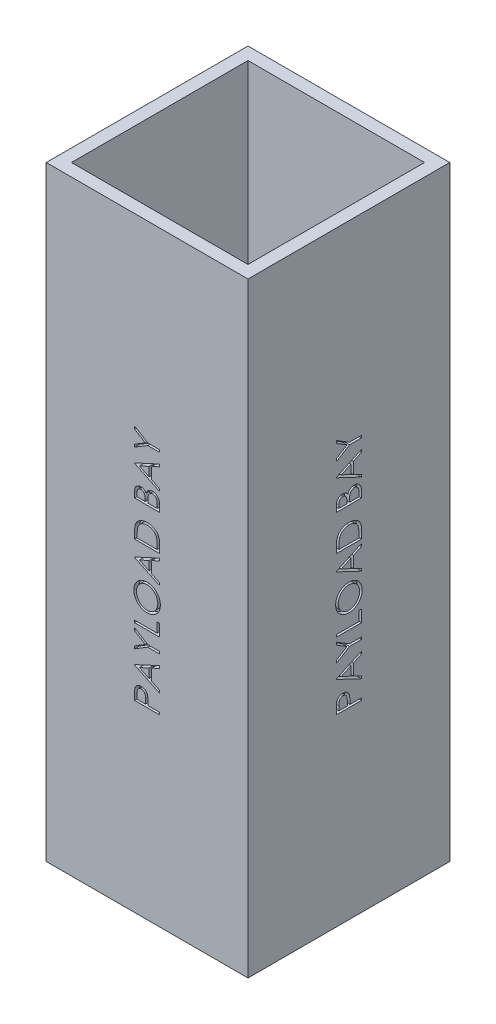
from build123d import *

# Parameters (mm, degrees)
SKETCH1_W           = 101.6
SKETCH1_H           = 101.6
SKETCH1_W_2         = 88.9
SKETCH1_H_2         = 88.9
BOSS_EXTRUDE1_DEPTH = 304.8
CUT_EXTRUDE1_DEPTH  = 2.54
CIRPATTERN1_COUNT   = 4


with BuildPart() as part:
    # Sketch1 → Boss-Extrude1 (new body)
    with BuildSketch(Plane(origin=(0, 0, 0), x_dir=(1, 0, 0), z_dir=(0, 1, 0))):
        Rectangle(SKETCH1_W, SKETCH1_H)
        Rectangle(SKETCH1_W_2, SKETCH1_H_2, mode=Mode.SUBTRACT)
    extrude(amount=BOSS_EXTRUDE1_DEPTH)

    # Sketch6 → Cut-Extrude1 (cut)
    with BuildSketch(Plane.ZY.offset(50.8)):
        with BuildLine():
            Line((-6.35, 92.482051282), (-6.35, 94.972696314))
            add(Edge.make_bspline(
                [(-6.35, 94.972696314), (-6.349811691, 95.144004459), (-6.349450882, 95.472238473), (-6.338511661, 95.942918818), (-6.323900522, 96.370399844), (-6.303646223, 96.753759798), (-6.279710024, 97.094178211), (-6.246138339, 97.390114698), (-6.211085266, 97.643895374), (-6.175447591, 97.795955919), (-6.159194712, 97.865304487)],
                knots=[0, 0, 0, 0, 0.000513909, 0.000984672, 0.001412348, 0.001797041, 0.002136358, 0.002435846, 0.002690583, 0.002904164, 0.002904164, 0.002904164, 0.002904164], degree=3))
            add(Edge.make_bspline(
                [(-6.159194712, 97.865304487), (-6.135165553, 97.953091687), (-6.087673454, 98.126597491), (-5.99256869, 98.376620926), (-5.879734333, 98.614446609), (-5.751382729, 98.841136022), (-5.601195819, 99.052560376), (-5.439164902, 99.255767619), (-5.254818851, 99.443584549), (-5.053971996, 99.618555122), (-4.839171698, 99.780275569), (-4.60651531, 99.916149986), (-4.36294889, 100.034954344), (-4.105162168, 100.132225501), (-3.832904869, 100.204560375), (-3.548111823, 100.258261731), (-3.250462794, 100.292503698), (-3.047042823, 100.295772087), (-2.943489583, 100.297435897)],
                knots=[0, 0, 0, 0, 0.000272928, 0.000539425, 0.000801167, 0.00106213, 0.001319735, 0.001578393, 0.001841062, 0.00210791, 0.002377077, 0.00264628, 0.002914809, 0.003189345, 0.003471382, 0.003758783, 0.004058271, 0.004368814, 0.004368814, 0.004368814, 0.004368814], degree=3))
            add(Edge.make_bspline(
                [(-2.943489583, 100.297435897), (-2.839067365, 100.295906728), (-2.634758241, 100.292914804), (-2.335862696, 100.257005426), (-2.050227394, 100.208635873), (-1.778485674, 100.134260855), (-1.522251307, 100.036849412), (-1.277608551, 99.922578249), (-1.048719455, 99.784752296), (-0.834753057, 99.626383914), (-0.635508519, 99.450210986), (-0.452429693, 99.256978896), (-0.286588236, 99.047467749), (-0.137612361, 98.822343383), (-0.008956718, 98.579411074), (0.106276931, 98.32235526), (0.20305478, 98.048941618), (0.25396386, 97.859738781), (0.279847756, 97.763541667)],
                knots=[0, 0, 0, 0, 0.000313086, 0.000612574, 0.000902017, 0.001181599, 0.001456135, 0.001723565, 0.001990583, 0.002256192, 0.00252113, 0.002787469, 0.003053674, 0.003321805, 0.003596116, 0.003877417, 0.00416629, 0.004465075, 0.004465075, 0.004465075, 0.004465075], degree=3))
            add(Edge.make_bspline(
                [(0.279847756, 97.763541667), (0.296755106, 97.683975863), (0.333808547, 97.509602778), (0.375455577, 97.222445764), (0.409610691, 96.88794002), (0.441484518, 96.507223684), (0.458373661, 96.079408932), (0.47820427, 95.605476968), (0.487561251, 95.083823846), (0.488152728, 94.719987058), (0.488461538, 94.530028045)],
                knots=[0, 0, 0, 0, 0.000243979, 0.000534694, 0.000869865, 0.001252695, 0.001680583, 0.002154115, 0.002675749, 0.003245626, 0.003245626, 0.003245626, 0.003245626], degree=3))
            Line((0.488461538, 94.530028045), (0.488461538, 93.621794872))
            Line((0.488461538, 93.621794872), (6.35, 93.621794872))
            Line((6.35, 93.621794872), (6.35, 92.482051282))
            Line((6.35, 92.482051282), (-6.35, 92.482051282))
        make_face()
        with BuildLine():
            Line((-5.047435897, 93.621794872), (-0.814102564, 93.621794872))
            Line((-0.814102564, 93.621794872), (-0.786117788, 95.8453125))
            add(Edge.make_bspline(
                [(-0.786117788, 95.8453125), (-0.786058006, 95.953879847), (-0.785942597, 96.163466872), (-0.800452377, 96.466211014), (-0.816979073, 96.747130601), (-0.841974741, 97.005169257), (-0.874740105, 97.24123239), (-0.915487111, 97.453280991), (-0.959785588, 97.644486591), (-1.033797354, 97.864431594), (-1.147598039, 98.111657023), (-1.313260324, 98.381731934), (-1.527867901, 98.608844847), (-1.768488369, 98.80501689), (-2.035447832, 98.963756171), (-2.322580965, 99.075740401), (-2.62563392, 99.144695668), (-2.832880378, 99.15330752), (-2.938401442, 99.157692308)],
                knots=[0, 0, 0, 0, 0.000325651, 0.000628662, 0.000909076, 0.001169816, 0.001406195, 0.001623739, 0.00181749, 0.001994481, 0.002318937, 0.002632302, 0.002940177, 0.003251283, 0.003561503, 0.003867638, 0.004172555, 0.00448885, 0.00448885, 0.00448885, 0.00448885], degree=3))
            add(Edge.make_bspline(
                [(-2.938401442, 99.157692308), (-3.040503948, 99.153110659), (-3.243471094, 99.144002909), (-3.540938354, 99.076309447), (-3.824816581, 98.962553668), (-4.089626181, 98.804878111), (-4.329717186, 98.61346686), (-4.538638533, 98.391169219), (-4.705467251, 98.137416482), (-4.81729303, 97.903335586), (-4.882763075, 97.693719024), (-4.930049703, 97.512545142), (-4.962657093, 97.306933975), (-4.993858298, 97.078839141), (-5.019043897, 96.828550238), (-5.036533738, 96.554476492), (-5.046662216, 96.257530593), (-5.04717176, 96.051390347), (-5.047435897, 95.94453125)],
                knots=[0, 0, 0, 0, 0.000306146, 0.00060858, 0.000909985, 0.001220206, 0.001529716, 0.001828533, 0.002131234, 0.002437391, 0.002603127, 0.00278947, 0.002998595, 0.003227067, 0.003480211, 0.003753009, 0.004050839, 0.004371402, 0.004371402, 0.004371402, 0.004371402], degree=3))
            Line((-5.047435897, 95.94453125), (-5.047435897, 93.621794872))
        make_face(mode=Mode.SUBTRACT)
        Polygon((-6.35, 108.112820513), (6.35, 113.974358974), (6.35, 112.735396635), (2.279487179, 110.857872596), (2.279487179, 105.100641026), (6.35, 103.169691506), (6.35, 101.925641026), (-6.35, 107.95), align=None)
        Polygon((-3.874619391, 108.018689904), (0.976923077, 105.71885016), (0.976923077, 110.257471955), align=None, mode=Mode.SUBTRACT)
        Polygon((-6.35, 114.951282051), (-6.35, 116.256390224), (-0.89296875, 119.594210737), (-6.35, 122.926943109), (-6.35, 124.232051282), (0.312920673, 120.161538462), (6.35, 120.161538462), (6.35, 119.021794872), (0.312920673, 119.021794872), align=None)
        Polygon((-6.35, 126.348717949), (-6.35, 127.488461538), (5.047435897, 127.488461538), (5.047435897, 132.373076923), (6.35, 132.373076923), (6.35, 126.348717949), align=None)
        with BuildLine():
            add(Edge.make_bspline(
                [(-6.675641026, 140.432692308), (-6.669785071, 140.667878789), (-6.658283492, 141.129804442), (-6.567334124, 141.808062537), (-6.41764098, 142.457525074), (-6.206242297, 143.078565423), (-5.932190469, 143.668821615), (-5.599295982, 144.229960687), (-5.205535771, 144.760300963), (-4.756691829, 145.256191897), (-4.26513446, 145.708559312), (-3.738912975, 146.105514067), (-3.184643364, 146.440382863), (-2.60229672, 146.714509446), (-1.99323266, 146.929716981), (-1.354037691, 147.078184212), (-0.688898346, 147.17303121), (-0.235229152, 147.184118924), (-0.005088141, 147.18974359)],
                knots=[0, 0, 0, 0, 0.000705368, 0.001385402, 0.0020488, 0.002702076, 0.003349741, 0.00399766, 0.004656078, 0.005327949, 0.006001364, 0.006657226, 0.007302086, 0.007940532, 0.008585026, 0.009236039, 0.009906328, 0.010596447, 0.010596447, 0.010596447, 0.010596447], degree=3))
            add(Edge.make_bspline(
                [(-0.005088141, 147.18974359), (0.223356266, 147.184117031), (0.673646657, 147.173026431), (1.334584132, 147.078107253), (1.969850898, 146.929054513), (2.578031024, 146.717174008), (3.159194899, 146.442837073), (3.71388411, 146.107475299), (4.241511135, 145.711273919), (4.736454933, 145.260827488), (5.189213913, 144.768333696), (5.588564969, 144.244134632), (5.923579539, 143.6898798), (6.200766497, 143.111312922), (6.411489139, 142.503890905), (6.56490218, 141.872033968), (6.658807614, 141.212299547), (6.669968316, 140.762882653), (6.675641026, 140.534455128)],
                knots=[0, 0, 0, 0, 0.000685036, 0.001350284, 0.001998823, 0.002640075, 0.00327852, 0.003923381, 0.004581277, 0.005254856, 0.005928271, 0.006585666, 0.00722835, 0.007867883, 0.008506734, 0.009153393, 0.009816123, 0.010501158, 0.010501158, 0.010501158, 0.010501158], degree=3))
            add(Edge.make_bspline(
                [(6.675641026, 140.534455128), (6.670018965, 140.304315456), (6.658936386, 139.850648902), (6.563935289, 139.184671659), (6.415376844, 138.545035274), (6.203071175, 137.933568914), (5.928688652, 137.349931598), (5.594118477, 136.792981869), (5.19712685, 136.264955249), (4.746579565, 135.770229483), (4.256099934, 135.317568107), (3.730558494, 134.922926944), (3.180265837, 134.588281533), (2.603694821, 134.314820298), (2.003632729, 134.098323545), (1.376076825, 133.950623205), (0.724604903, 133.855061322), (0.281037815, 133.844049165), (0.055969551, 133.838461538)],
                knots=[0, 0, 0, 0, 0.000690119, 0.001360408, 0.002013897, 0.002657552, 0.003298299, 0.003945339, 0.004603236, 0.005276814, 0.005950229, 0.006602529, 0.007245213, 0.007879059, 0.008513962, 0.009155077, 0.009810248, 0.010485118, 0.010485118, 0.010485118, 0.010485118], degree=3))
            add(Edge.make_bspline(
                [(0.055969551, 133.838461538), (-0.095097562, 133.840401502), (-0.395326011, 133.844256954), (-0.841156245, 133.890672524), (-1.279816632, 133.958024983), (-1.710059786, 134.054551923), (-2.130832502, 134.180795971), (-2.545036699, 134.329756185), (-2.948474782, 134.511692195), (-3.343057946, 134.717361975), (-3.722635205, 134.946911965), (-4.081426835, 135.200461113), (-4.422443595, 135.469103735), (-4.736848437, 135.763610906), (-5.033787705, 136.074276293), (-5.308698135, 136.406139551), (-5.564058671, 136.757175695), (-5.794183909, 137.128895187), (-6.002315626, 137.512138642), (-6.180920628, 137.907205807), (-6.33421348, 138.308731081), (-6.45845876, 138.718595089), (-6.556546433, 139.135709433), (-6.623338831, 139.56098448), (-6.669872784, 139.994081427), (-6.673710006, 140.285859641), (-6.675641026, 140.432692308)],
                knots=[0, 0, 0, 0, 0.000453023, 0.000900331, 0.00134327, 0.001783953, 0.002221843, 0.002660465, 0.003103469, 0.003548398, 0.003994743, 0.004433047, 0.004865726, 0.005295975, 0.005724256, 0.006154227, 0.006587795, 0.007025471, 0.007464852, 0.007895214, 0.008325184, 0.00875333, 0.009179133, 0.00960951, 0.010044159, 0.010484467, 0.010484467, 0.010484467, 0.010484467], degree=3))
        make_face()
        with BuildLine():
            add(Edge.make_bspline(
                [(-5.373076923, 140.488661859), (-5.371612874, 140.368138647), (-5.368698771, 140.128244435), (-5.330103131, 139.771634762), (-5.275488499, 139.419606801), (-5.196168901, 139.072841773), (-5.093572448, 138.730612447), (-4.969833028, 138.392766886), (-4.820275395, 138.060463451), (-4.652079665, 137.734117284), (-4.461036223, 137.421265912), (-4.258166746, 137.121155899), (-4.035933534, 136.841593359), (-3.799142721, 136.578737887), (-3.545739327, 136.333243177), (-3.277387483, 136.105217516), (-2.992926494, 135.894847893), (-2.693527038, 135.704666015), (-2.380860728, 135.535418989), (-2.060904396, 135.383885031), (-1.729897889, 135.258269162), (-1.389906788, 135.158762678), (-1.042429358, 135.074304473), (-0.685572416, 135.021326036), (-0.320566176, 134.982350109), (-0.073887757, 134.979597426), (0.05088141, 134.978205128)],
                knots=[0, 0, 0, 0, 0.000361401, 0.000719348, 0.001074863, 0.001429731, 0.001785501, 0.002146095, 0.002508248, 0.002878058, 0.003246738, 0.003607323, 0.00396412, 0.004317168, 0.004668001, 0.005021764, 0.005372855, 0.005728561, 0.006084895, 0.00643885, 0.006789913, 0.007145683, 0.007501125, 0.007861666, 0.008227207, 0.008601324, 0.008601324, 0.008601324, 0.008601324], degree=3))
            add(Edge.make_bspline(
                [(0.05088141, 134.978205128), (0.234345869, 134.98284164), (0.595277215, 134.991963092), (1.124266852, 135.071486696), (1.63314324, 135.194954947), (2.118873279, 135.373960588), (2.583622971, 135.602317606), (3.025583679, 135.880866807), (3.444625029, 136.212159116), (3.837627676, 136.588256745), (4.19619396, 136.999509589), (4.511375607, 137.435990281), (4.776641272, 137.894245547), (4.998397407, 138.371634123), (5.165459253, 138.87223187), (5.284574271, 139.392829147), (5.361776101, 139.933437463), (5.369274234, 140.301830698), (5.373076923, 140.488661859)],
                knots=[0, 0, 0, 0, 0.000550108, 0.001082232, 0.001601154, 0.002118677, 0.00263181, 0.003152009, 0.003682843, 0.004231661, 0.004781633, 0.005317521, 0.005844193, 0.006367833, 0.006893982, 0.007424089, 0.007968455, 0.008528619, 0.008528619, 0.008528619, 0.008528619], degree=3))
            add(Edge.make_bspline(
                [(5.373076923, 140.488661859), (5.371352914, 140.614245402), (5.367933685, 140.863315285), (5.333446658, 141.233768939), (5.278253288, 141.597582943), (5.198393676, 141.954085094), (5.099767851, 142.303742487), (4.97743268, 142.645500082), (4.830782133, 142.979244366), (4.667344949, 143.306616436), (4.481684714, 143.620286113), (4.281550104, 143.918575726), (4.063238117, 144.197656623), (3.829627504, 144.460388767), (3.57700307, 144.704162974), (3.310282099, 144.9315394), (3.025217373, 145.138271673), (2.727044186, 145.327808831), (2.416657403, 145.499120929), (2.095821442, 145.646271725), (1.766257055, 145.771941549), (1.427722103, 145.873245665), (1.080978091, 145.952668472), (0.725528754, 146.007384366), (0.362093818, 146.045660851), (0.116280345, 146.048545747), (-0.007632212, 146.05)],
                knots=[0, 0, 0, 0, 0.00037666, 0.00074703, 0.001115112, 0.001479909, 0.001842294, 0.002204411, 0.002567866, 0.002935359, 0.003301431, 0.003660587, 0.004012239, 0.004363588, 0.004714421, 0.005064598, 0.005414184, 0.00576989, 0.006123991, 0.006476875, 0.006827938, 0.007181271, 0.007536139, 0.007894167, 0.008259708, 0.008631282, 0.008631282, 0.008631282, 0.008631282], degree=3))
            add(Edge.make_bspline(
                [(-0.007632212, 146.05), (-0.130697041, 146.048544533), (-0.374818801, 146.045657346), (-0.735719484, 146.007403224), (-1.088609709, 145.952608564), (-1.432104078, 145.873641023), (-1.766290161, 145.77185904), (-2.090854054, 145.646356428), (-2.407005009, 145.498364107), (-2.713961172, 145.328516926), (-3.008510573, 145.137597379), (-3.290092515, 144.928972715), (-3.553442649, 144.699057084), (-3.804973342, 144.45435931), (-4.03965346, 144.188996329), (-4.256576238, 143.902921828), (-4.465515493, 143.603258692), (-4.650429047, 143.283230258), (-4.822051388, 142.954134185), (-4.968471586, 142.616134055), (-5.094225799, 142.274057007), (-5.196475173, 141.926535353), (-5.275184667, 141.573733358), (-5.330152005, 141.215856192), (-5.368685515, 140.854153049), (-5.371608475, 140.610878865), (-5.373076923, 140.488661859)],
                knots=[0, 0, 0, 0, 0.000369031, 0.00073204, 0.001087555, 0.001439943, 0.001788407, 0.002134718, 0.002482986, 0.00283486, 0.003186283, 0.003535331, 0.003885231, 0.004234241, 0.004587492, 0.004946738, 0.00531086, 0.005682608, 0.006054677, 0.006423813, 0.006786796, 0.007147444, 0.007509758, 0.007870298, 0.008233308, 0.008599795, 0.008599795, 0.008599795, 0.008599795], degree=3))
        make_face(mode=Mode.SUBTRACT)
        Polygon((-6.35, 155.005128205), (6.35, 160.866666667), (6.35, 159.627704327), (2.279487179, 157.750180288), (2.279487179, 151.992948718), (6.35, 150.061999199), (6.35, 148.817948718), (-6.35, 154.842307692), align=None)
        Polygon((-3.874619391, 154.910997596), (0.976923077, 152.611157853), (0.976923077, 157.149779647), align=None, mode=Mode.SUBTRACT)
        with BuildLine():
            Line((6.35, 162.820512821), (-6.35, 162.820512821))
            Line((-6.35, 162.820512821), (-6.35, 165.384935897))
            add(Edge.make_bspline(
                [(-6.35, 165.384935897), (-6.348394103, 165.607980512), (-6.345291519, 166.038901546), (-6.325619614, 166.66160957), (-6.290819923, 167.237767793), (-6.2401305, 167.765481311), (-6.177889492, 168.246198851), (-6.099873739, 168.678574372), (-6.00775095, 169.064843576), (-5.929208887, 169.302404118), (-5.892067308, 169.41474359)],
                knots=[0, 0, 0, 0, 0.000669134, 0.001292764, 0.001868826, 0.002400433, 0.002882928, 0.003322552, 0.003718071, 0.004072903, 0.004072903, 0.004072903, 0.004072903], degree=3))
            add(Edge.make_bspline(
                [(-5.892067308, 169.41474359), (-5.836093327, 169.561694877), (-5.725414669, 169.852265085), (-5.51631439, 170.265755961), (-5.280367806, 170.656337905), (-5.012145128, 171.020896847), (-4.715148895, 171.36034751), (-4.391500844, 171.678542555), (-4.034011275, 171.96763688), (-3.649043287, 172.232133132), (-3.241529407, 172.470675187), (-2.812137035, 172.67800451), (-2.363076518, 172.850195854), (-1.895588611, 172.993136678), (-1.408647571, 173.105791053), (-0.9016858, 173.182651182), (-0.376707035, 173.233345923), (-0.02047398, 173.238440622), (0.160276442, 173.241025641)],
                knots=[0, 0, 0, 0, 0.000471477, 0.000932263, 0.001387773, 0.001839114, 0.00228809, 0.002739654, 0.00319897, 0.003665423, 0.00413972, 0.004614208, 0.005094222, 0.005581098, 0.006079742, 0.006592118, 0.007118421, 0.007660523, 0.007660523, 0.007660523, 0.007660523], degree=3))
            add(Edge.make_bspline(
                [(0.160276442, 173.241025641), (0.317252935, 173.238743386), (0.626591509, 173.234245964), (1.082488494, 173.193862471), (1.52486052, 173.135165446), (1.951601475, 173.044291121), (2.366448593, 172.933972212), (2.764986355, 172.792592467), (3.150849201, 172.630613026), (3.518898525, 172.441806471), (3.867366737, 172.234246367), (4.196106488, 172.012889743), (4.497822934, 171.772716402), (4.780422415, 171.520834747), (5.036355603, 171.251170688), (5.270287817, 170.967007346), (5.478302523, 170.667240384), (5.663668473, 170.350014161), (5.829436114, 170.01109204), (5.967706215, 169.639813205), (6.087462238, 169.237936329), (6.182728161, 168.80316961), (6.259560811, 168.337063728), (6.310716285, 167.838325694), (6.345409359, 167.307898054), (6.348440074, 166.943663461), (6.35, 166.756189904)],
                knots=[0, 0, 0, 0, 0.000470825, 0.00092781, 0.001372149, 0.001808729, 0.0022358, 0.002659019, 0.003076254, 0.003490407, 0.003898792, 0.004292531, 0.004678333, 0.00505483, 0.005427317, 0.005792478, 0.006158046, 0.006520636, 0.006893843, 0.007288379, 0.00770775, 0.008150915, 0.008622694, 0.009124186, 0.009654385, 0.010216717, 0.010216717, 0.010216717, 0.010216717], degree=3))
            Line((6.35, 166.756189904), (6.35, 162.820512821))
        make_face()
        with BuildLine():
            Line((5.047435897, 163.96025641), (5.047435897, 165.418008814))
            add(Edge.make_bspline(
                [(5.047435897, 165.418008814), (5.046535662, 165.627480331), (5.04480418, 166.030370771), (5.029610614, 166.609701218), (5.004784155, 167.139035028), (4.970040301, 167.618447362), (4.924071326, 168.047667536), (4.872818108, 168.427592571), (4.808964501, 168.75697708), (4.751085305, 168.956292466), (4.724338942, 169.048397436)],
                knots=[0, 0, 0, 0, 0.000628406, 0.001208655, 0.001738433, 0.002218042, 0.002650422, 0.003033235, 0.00336802, 0.003655635, 0.003655635, 0.003655635, 0.003655635], degree=3))
            add(Edge.make_bspline(
                [(4.724338942, 169.048397436), (4.683511867, 169.164324362), (4.602832871, 169.393409301), (4.45566639, 169.723177636), (4.281342714, 170.030725124), (4.087567265, 170.321407724), (3.867514454, 170.591116069), (3.625936061, 170.842993512), (3.36172837, 171.076731682), (3.075319806, 171.288730377), (2.769816125, 171.480752404), (2.444677018, 171.645595261), (2.104473453, 171.789151793), (1.746451287, 171.902822569), (1.373234633, 171.992446996), (0.9828882, 172.055268709), (0.575757403, 172.094269377), (0.298593328, 172.098919006), (0.157732372, 172.101282051)],
                knots=[0, 0, 0, 0, 0.000368636, 0.000728467, 0.00108158, 0.001428031, 0.001775294, 0.002124361, 0.00247402, 0.002832229, 0.003192239, 0.003555195, 0.003924673, 0.00429879, 0.004680748, 0.005075153, 0.005483989, 0.005906496, 0.005906496, 0.005906496, 0.005906496], degree=3))
            add(Edge.make_bspline(
                [(0.157732372, 172.101282051), (0.009202315, 172.099419551), (-0.282586297, 172.095760654), (-0.710723963, 172.049771013), (-1.122496609, 171.982564226), (-1.517931775, 171.885377708), (-1.897800939, 171.761531376), (-2.260003161, 171.606973676), (-2.608363686, 171.430383372), (-2.934842098, 171.220276978), (-3.243608523, 170.990168968), (-3.526473502, 170.734797806), (-3.784081392, 170.458220695), (-4.020444041, 170.163454241), (-4.226052236, 169.842191052), (-4.409972479, 169.501999089), (-4.566058713, 169.137887653), (-4.649076301, 168.8845673), (-4.691266026, 168.755829327)],
                knots=[0, 0, 0, 0, 0.000445394, 0.00087498, 0.001290296, 0.001696304, 0.002095342, 0.002487525, 0.00287666, 0.003265537, 0.003650709, 0.004030799, 0.004406986, 0.004783646, 0.005162584, 0.005549584, 0.005942765, 0.00634906, 0.00634906, 0.00634906, 0.00634906], degree=3))
            add(Edge.make_bspline(
                [(-4.691266026, 168.755829327), (-4.720717064, 168.649326596), (-4.783338052, 168.422872568), (-4.851647261, 168.053340799), (-4.911897871, 167.637451542), (-4.962908471, 167.173358341), (-4.999511037, 166.661590218), (-5.026984093, 166.101753579), (-5.045513874, 165.493606442), (-5.046779183, 165.072029819), (-5.047435897, 164.85322516)],
                knots=[0, 0, 0, 0, 0.000331365, 0.000704572, 0.001126244, 0.001592052, 0.002104832, 0.002665226, 0.00327352, 0.00392991, 0.00392991, 0.00392991, 0.00392991], degree=3))
            Line((-5.047435897, 164.85322516), (-5.047435897, 163.96025641))
            Line((-5.047435897, 163.96025641), (5.047435897, 163.96025641))
        make_face(mode=Mode.SUBTRACT)
        with BuildLine():
            Line((-6.35, 180.730769231), (-6.35, 183.20869391))
            add(Edge.make_bspline(
                [(-6.35, 183.20869391), (-6.349372317, 183.329993444), (-6.34815571, 183.565102129), (-6.32884905, 183.906958107), (-6.303182672, 184.227265278), (-6.260128703, 184.525457622), (-6.215487417, 184.80347543), (-6.149964695, 185.058496238), (-6.077592462, 185.292656163), (-5.966237959, 185.573834305), (-5.793303013, 185.892869434), (-5.536824054, 186.235772502), (-5.229326494, 186.533844772), (-4.878908769, 186.787294554), (-4.493409562, 186.990693397), (-4.081123013, 187.135981885), (-3.64898535, 187.229320743), (-3.352715027, 187.238799389), (-3.202984776, 187.243589744)],
                knots=[0, 0, 0, 0, 0.000363838, 0.000705208, 0.00102698, 0.001327407, 0.001608892, 0.001871129, 0.002116536, 0.002343771, 0.002777466, 0.0032008, 0.003623583, 0.004057151, 0.004494139, 0.004926249, 0.005365321, 0.005813951, 0.005813951, 0.005813951, 0.005813951], degree=3))
            add(Edge.make_bspline(
                [(-3.202984776, 187.243589744), (-3.062737383, 187.239599728), (-2.787138031, 187.23175897), (-2.384737295, 187.157696306), (-2.002077719, 187.040148273), (-1.639486801, 186.87769215), (-1.303714203, 186.668376526), (-0.995800058, 186.417586986), (-0.727381826, 186.116265358), (-0.577377362, 185.890393651), (-0.501181891, 185.775661058)],
                knots=[0, 0, 0, 0, 0.000420396, 0.000826117, 0.001222837, 0.001619092, 0.002014431, 0.002406622, 0.002806568, 0.003219445, 0.003219445, 0.003219445, 0.003219445], degree=3))
            add(Edge.make_bspline(
                [(-0.501181891, 185.775661058), (-0.445773816, 185.919920678), (-0.339764444, 186.195925067), (-0.152634166, 186.57596648), (0.051636421, 186.902202218), (0.271263785, 187.181005131), (0.511490195, 187.418194242), (0.774267381, 187.623613728), (1.059380217, 187.801202875), (1.365780824, 187.952330012), (1.690871704, 188.071042262), (2.030682193, 188.15829412), (2.383909628, 188.209905491), (2.623616838, 188.216946074), (2.745052083, 188.220512821)],
                knots=[0, 0, 0, 0, 0.000463447, 0.000886689, 0.001268545, 0.0016162, 0.001949007, 0.002278795, 0.002614805, 0.002954998, 0.003301897, 0.00365114, 0.00400589, 0.004370127, 0.004370127, 0.004370127, 0.004370127], degree=3))
            add(Edge.make_bspline(
                [(2.745052083, 188.220512821), (2.869029524, 188.21696904), (3.112958611, 188.209996552), (3.471291465, 188.158532445), (3.813764183, 188.071454355), (4.142434121, 187.951303705), (4.456612174, 187.795568463), (4.755160179, 187.603304589), (5.038699261, 187.377211083), (5.307729832, 187.121688874), (5.553901262, 186.836929363), (5.765525674, 186.523106054), (5.947492508, 186.188816177), (6.095643415, 185.829786154), (6.209941742, 185.446932515), (6.289576238, 185.040468299), (6.343323875, 184.611062893), (6.347736865, 184.316385354), (6.35, 184.165264423)],
                knots=[0, 0, 0, 0, 0.000371861, 0.000731647, 0.001083355, 0.001430255, 0.001779543, 0.002133105, 0.002493475, 0.002865962, 0.003244832, 0.003620227, 0.003999302, 0.004384828, 0.004783241, 0.005195859, 0.005626281, 0.006079382, 0.006079382, 0.006079382, 0.006079382], degree=3))
            Line((6.35, 184.165264423), (6.35, 180.730769231))
            Line((6.35, 180.730769231), (-6.35, 180.730769231))
        make_face()
        with BuildLine():
            Line((-5.047435897, 181.870512821), (-0.976923077, 181.870512821))
            Line((-0.976923077, 181.870512821), (-0.976923077, 182.636278045))
            add(Edge.make_bspline(
                [(-0.976923077, 182.636278045), (-0.978374226, 182.748215103), (-0.981178141, 182.964500309), (-0.989210049, 183.277718217), (-1.011700083, 183.568457579), (-1.034183694, 183.83621648), (-1.070739951, 184.080573468), (-1.114254566, 184.300986513), (-1.160274294, 184.500916987), (-1.238545357, 184.731469368), (-1.354184303, 184.993027832), (-1.533820739, 185.271677561), (-1.747610778, 185.518470549), (-1.996602328, 185.724374206), (-2.267797908, 185.894378417), (-2.558816675, 186.013471713), (-2.863802254, 186.092867668), (-3.073579537, 186.100149172), (-3.180088141, 186.103846154)],
                knots=[0, 0, 0, 0, 0.000335856, 0.000648942, 0.000939679, 0.001210548, 0.001454845, 0.001680365, 0.001884605, 0.002069641, 0.0024101, 0.002739663, 0.003060599, 0.003385683, 0.003705519, 0.004016874, 0.004326007, 0.004644839, 0.004644839, 0.004644839, 0.004644839], degree=3))
            add(Edge.make_bspline(
                [(-3.180088141, 186.103846154), (-3.250585181, 186.101969054), (-3.388872822, 186.098286917), (-3.591119209, 186.067034672), (-3.781156629, 186.01639774), (-3.960808966, 185.947821684), (-4.125611427, 185.854136614), (-4.283438701, 185.74554331), (-4.424837705, 185.611469459), (-4.556615938, 185.459954103), (-4.674557016, 185.286593511), (-4.77225292, 185.087652627), (-4.860797869, 184.868274376), (-4.926345062, 184.622506905), (-4.983983541, 184.355442602), (-5.020198184, 184.063465315), (-5.043502651, 183.748425244), (-5.046095572, 183.530142044), (-5.047435897, 183.417307692)],
                knots=[0, 0, 0, 0, 0.000211403, 0.00041469, 0.000612163, 0.000800665, 0.000989698, 0.001179568, 0.001373986, 0.00157239, 0.001781252, 0.00200084, 0.002236108, 0.002489814, 0.002762742, 0.003055266, 0.00337156, 0.003710008, 0.003710008, 0.003710008, 0.003710008], degree=3))
            Line((-5.047435897, 183.417307692), (-5.047435897, 181.870512821))
        make_face(mode=Mode.SUBTRACT)
        with BuildLine():
            Line((0.325641026, 181.870512821), (5.047435897, 181.870512821))
            Line((5.047435897, 181.870512821), (5.047435897, 183.493629808))
            add(Edge.make_bspline(
                [(5.047435897, 183.493629808), (5.045904986, 183.609800616), (5.042954355, 183.833704534), (5.036034513, 184.157237907), (5.009857802, 184.456320822), (4.985709904, 184.73189678), (4.944418036, 184.983234398), (4.905449249, 185.212266982), (4.847602867, 185.415234803), (4.768099821, 185.652754112), (4.640825315, 185.9182458), (4.454878463, 186.208380427), (4.225391341, 186.461373325), (3.964393202, 186.678544111), (3.681391572, 186.857762875), (3.380086158, 186.98636929), (3.066336778, 187.066289903), (2.852362575, 187.075933072), (2.745052083, 187.080769231)],
                knots=[0, 0, 0, 0, 0.000348575, 0.000671832, 0.000970368, 0.00124908, 0.001501302, 0.001734317, 0.001945399, 0.00213366, 0.002485313, 0.002825429, 0.003164106, 0.003505476, 0.003841486, 0.004165184, 0.004484806, 0.004806367, 0.004806367, 0.004806367, 0.004806367], degree=3))
            add(Edge.make_bspline(
                [(2.745052083, 187.080769231), (2.677946231, 187.079770435), (2.54481695, 187.077788953), (2.34920062, 187.047769991), (2.159617461, 187.004342067), (1.975277451, 186.947146241), (1.799280024, 186.867189559), (1.630950229, 186.769169369), (1.466897116, 186.656967846), (1.256812893, 186.483862119), (1.01776619, 186.228402227), (0.786615655, 185.865365211), (0.597190031, 185.454858428), (0.517108985, 185.156426067), (0.475741186, 185.002263622)],
                knots=[0, 0, 0, 0, 0.000201126, 0.000399009, 0.000592174, 0.000784466, 0.000976909, 0.00117066, 0.001368248, 0.001572487, 0.001986491, 0.00241129, 0.002858707, 0.003336803, 0.003336803, 0.003336803, 0.003336803], degree=3))
            add(Edge.make_bspline(
                [(0.475741186, 185.002263622), (0.463204167, 184.940472331), (0.436021324, 184.806496067), (0.407327657, 184.588028561), (0.381764154, 184.338615551), (0.362855097, 184.057681111), (0.343309639, 183.744869802), (0.33570843, 183.399513554), (0.326639687, 183.023022727), (0.325982428, 182.761793261), (0.325641026, 182.626101763)],
                knots=[0, 0, 0, 0, 0.000189102, 0.000410011, 0.000660625, 0.000941212, 0.001254639, 0.001600782, 0.001977382, 0.002384441, 0.002384441, 0.002384441, 0.002384441], degree=3))
            Line((0.325641026, 182.626101763), (0.325641026, 181.870512821))
        make_face(mode=Mode.SUBTRACT)
        Polygon((-6.35, 196.035897436), (6.35, 201.897435897), (6.35, 200.658473558), (2.279487179, 198.780949519), (2.279487179, 193.023717949), (6.35, 191.092768429), (6.35, 189.848717949), (-6.35, 195.873076923), align=None)
        Polygon((-3.874619391, 195.941766827), (0.976923077, 193.641927083), (0.976923077, 198.180548878), align=None, mode=Mode.SUBTRACT)
        Polygon((-6.35, 202.874358974), (-6.35, 204.179467147), (-0.89296875, 207.51728766), (-6.35, 210.850020032), (-6.35, 212.155128205), (0.312920673, 208.084615385), (6.35, 208.084615385), (6.35, 206.944871795), (0.312920673, 206.944871795), align=None)
    cut_extrude1 = extrude(amount=-CUT_EXTRUDE1_DEPTH, mode=Mode.SUBTRACT)

    # CirPattern1: Cut-Extrude1 ×4 about axis
    cirpattern1_axis = Axis((0, 0, 0), (0, 1, 0))
    for i in range(1, CIRPATTERN1_COUNT):
        add(cut_extrude1.rotate(cirpattern1_axis, i * 360 / CIRPATTERN1_COUNT), mode=Mode.SUBTRACT)


solid = part.part
